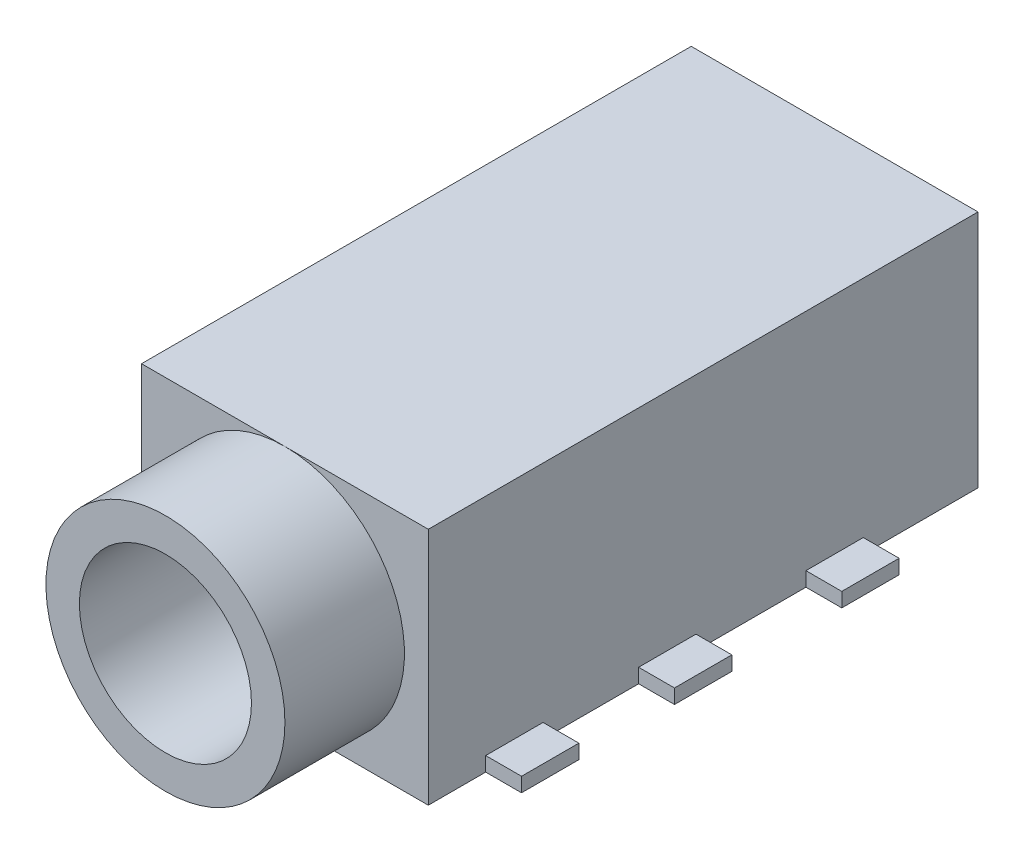
from build123d import *

# Parameters (mm, degrees)
SKETCH1_W           = 6
SKETCH1_H           = 5
BOSS_EXTRUDE1_DEPTH = 11.5
SKETCH2_R           = 2.5
SKETCH2_R_2         = 1.8
BOSS_EXTRUDE2_DEPTH = 2.5
SKETCH3_R           = 1.8
CUT_EXTRUDE1_DEPTH  = 10
SKETCH4_W           = 0.75
SKETCH4_H           = 1.2
BOSS_EXTRUDE3_DEPTH = 0.3
SKETCH5_R           = 0.75
BOSS_EXTRUDE4_DEPTH = 0.6


with BuildPart() as part:
    # Sketch1 → Boss-Extrude1 (new body)
    with BuildSketch(Plane.XY):
        Rectangle(SKETCH1_W, SKETCH1_H)
    extrude(amount=BOSS_EXTRUDE1_DEPTH)

    # Sketch2 → Boss-Extrude2 (add)
    with BuildSketch(Plane.XY.offset(11.5)):
        Circle(SKETCH2_R)
        Circle(SKETCH2_R_2, mode=Mode.SUBTRACT)
    extrude(amount=BOSS_EXTRUDE2_DEPTH)

    # Sketch3 → Cut-Extrude1 (cut)
    with BuildSketch(Plane.XY.offset(11.5)):
        Circle(SKETCH3_R)
    extrude(amount=-CUT_EXTRUDE1_DEPTH, mode=Mode.SUBTRACT)

    # Sketch4 → Boss-Extrude3 (add)
    with BuildSketch(Plane.XZ.offset(2.5)):
        with Locations((3.375, 9.7)):
            Rectangle(SKETCH4_W, SKETCH4_H)
        with Locations((3.375, 6.5)):
            Rectangle(SKETCH4_W, SKETCH4_H)
        with Locations((3.375, 3)):
            Rectangle(SKETCH4_W, SKETCH4_H)
        with Locations((-3.375, 3)):
            Rectangle(SKETCH4_W, SKETCH4_H)
        with Locations((-3.375, 6.5)):
            Rectangle(SKETCH4_W, SKETCH4_H)
        with Locations((-3.375, 9.7)):
            Rectangle(SKETCH4_W, SKETCH4_H)
    extrude(amount=-BOSS_EXTRUDE3_DEPTH)

    # Sketch5 → Boss-Extrude4 (add)
    with BuildSketch(Plane.XZ.offset(2.5)):
        with Locations((0, 9)):
            Circle(SKETCH5_R)
        with Locations((0, 3)):
            Circle(SKETCH5_R)
    extrude(amount=BOSS_EXTRUDE4_DEPTH)


solid = part.part
